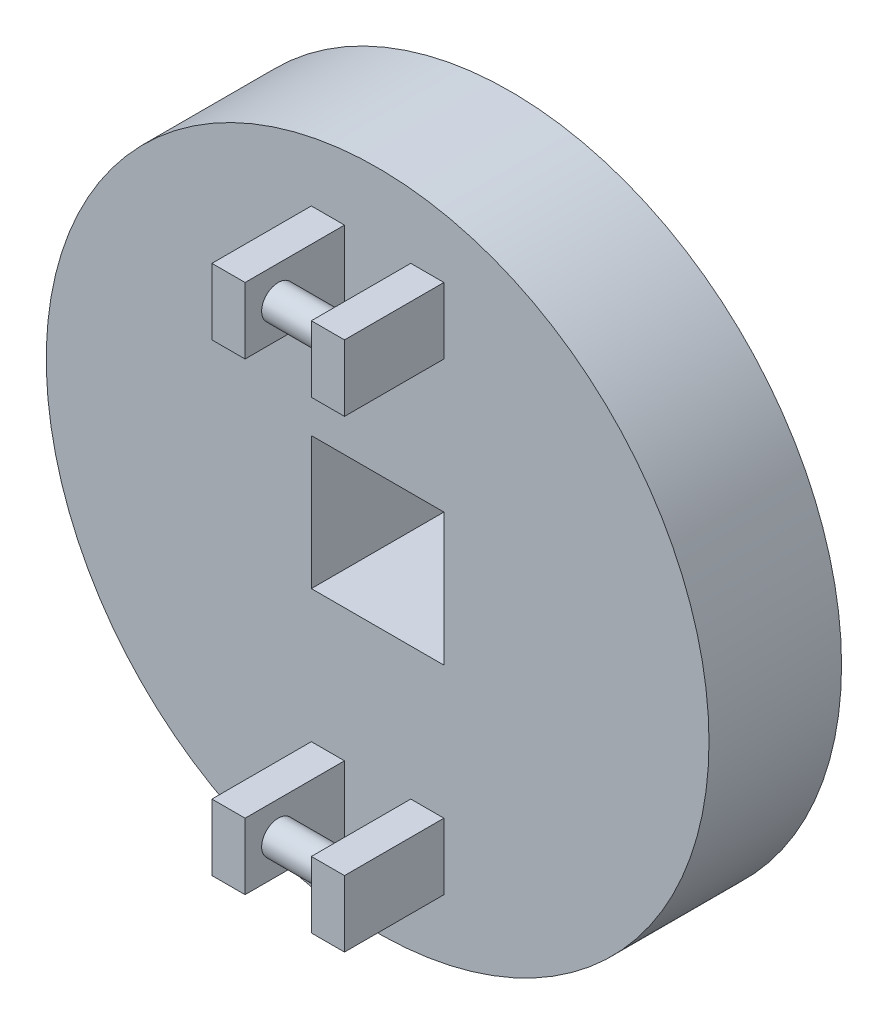
from build123d import *

# Parameters (mm, degrees)
SKETCH1_R           = 63.5
BOSS_EXTRUDE1_DEPTH = 12.7
SKETCH3_W           = 6.35
SKETCH3_H           = 12.7
BOSS_EXTRUDE2_DEPTH = 19.05
SKETCH4_R           = 3.175
BOSS_EXTRUDE3_DEPTH = 12.7
SKETCH5_W           = 25.4
SKETCH5_H           = 25.4
CUT_EXTRUDE1_DEPTH  = 26.4


with BuildPart() as part:
    # Sketch1 → Boss-Extrude1 (new body, symmetric)
    with BuildSketch(Plane.XY):
        Circle(SKETCH1_R)
    extrude(amount=BOSS_EXTRUDE1_DEPTH, both=True)

    # Sketch3 → Boss-Extrude2 (add)
    with BuildSketch(Plane.XY.offset(12.7)):
        with Locations((-9.525, 44.45)):
            Rectangle(SKETCH3_W, SKETCH3_H)
        with Locations((9.525, 44.45)):
            Rectangle(SKETCH3_W, SKETCH3_H)
    boss_extrude2 = extrude(amount=BOSS_EXTRUDE2_DEPTH)

    # Sketch4 → Boss-Extrude3 (add)
    with BuildSketch(Plane(origin=(-6.35, 0, 0), x_dir=(0, 0, -1), z_dir=(1, 0, 0))):
        with Locations((-25.4, 44.45)):
            Circle(SKETCH4_R)
    boss_extrude3 = extrude(amount=BOSS_EXTRUDE3_DEPTH)

    # Mirror1: Boss-Extrude2, Boss-Extrude3 across plane
    add(boss_extrude2.mirror(Plane.ZX))
    add(boss_extrude3.mirror(Plane.ZX))

    # Sketch5 → Cut-Extrude1 (cut, through all)
    with BuildSketch(Plane.XY.offset(12.7)):
        Rectangle(SKETCH5_W, SKETCH5_H)
    extrude(amount=-CUT_EXTRUDE1_DEPTH, mode=Mode.SUBTRACT)


solid = part.part
